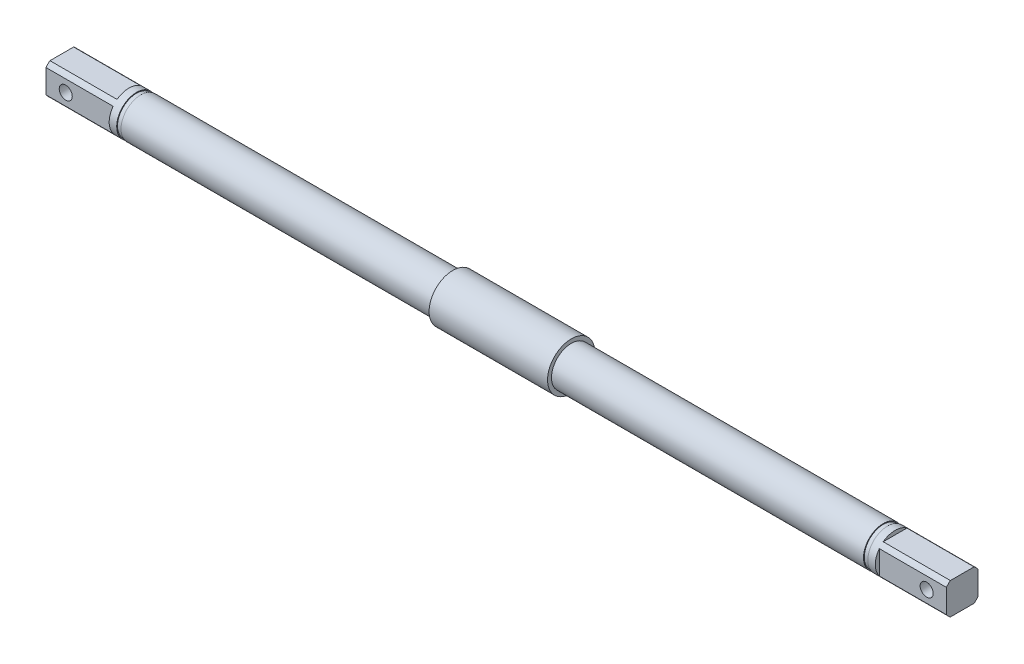
from build123d import *

# Parameters (mm, degrees)
SKETCH_2_OUTSIDE_W   = 59.726
SKETCH_2_OUTSIDE_H   = 59.726
SKETCH_2_OUTSIDE_W_2 = 8
SKETCH_2_OUTSIDE_H_2 = 8
CUT_EXTRUDE_1_DEPTH  = 17
HOLE_WIZARD_M4_1_D   = 3.3


with BuildPart() as part:
    # 草图1 → 旋转1 (revolve)
    with BuildSketch(Plane.XY):
        Polygon((114, 0), (114, 5), (95.1, 5), (95.1, 4.8), (94, 4.8), (94, 5), (15, 5), (15, 6), (-15, 6), (-15, 5), (-94, 5), (-94, 4.8), (-95.1, 4.8), (-95.1, 5), (-114, 5), (-114, 0), align=None)
    revolve(axis=Axis((-114, 0, 0), (1, 0, 0)))

    # 草图2 outside → 切除-拉伸1 (cut)
    with BuildSketch(Plane(origin=(114, 0, 0), x_dir=(0, 0, -1), z_dir=(1, 0, 0))):
        Rectangle(SKETCH_2_OUTSIDE_W, SKETCH_2_OUTSIDE_H)
        Rectangle(SKETCH_2_OUTSIDE_W_2, SKETCH_2_OUTSIDE_H_2, mode=Mode.SUBTRACT)
    cut_extrude_1 = extrude(amount=-CUT_EXTRUDE_1_DEPTH, mode=Mode.SUBTRACT)

    # 镜向2: 切除-拉伸1 across plane
    add(cut_extrude_1.mirror(Plane(origin=(0, 0, 0), x_dir=(0, 0, 1), z_dir=(1, 0, 0))), mode=Mode.SUBTRACT)

    # M4 螺纹孔1 (through all)
    with Locations(Plane.XY.offset(4)):
        with Locations((109, 0), (-109, 0)):
            Hole(HOLE_WIZARD_M4_1_D / 2)


solid = part.part
